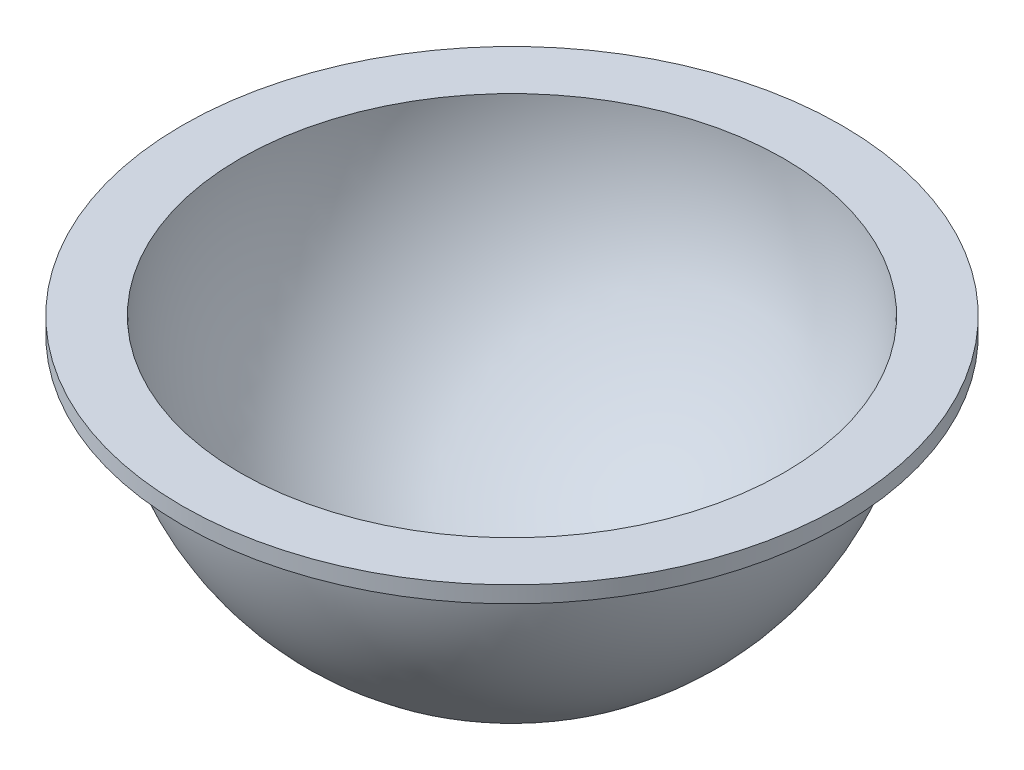
from build123d import *

# Parameters (mm, degrees)
SKETCH_2_W          = 150
SKETCH_2_H          = 150
CUT_EXTRUDE_1_DEPTH = 70
SHELL_1_T           = -4
SKETCH_3_R          = 80
SKETCH_3_R_2        = 66
EXTRUDE_1_DEPTH     = 4


with BuildPart() as part:
    # 草图1 → 旋转1 (revolve)
    with BuildSketch(Plane.XY):
        with BuildLine():
            Line((0, 70), (0, -70))
            ThreePointArc((0, -70), (70, 0), (0, 70))
        make_face()
    revolve(axis=Axis((0, 70, 0), (0, -1, 0)))

    # 草图2 → 切除-拉伸1 (cut)
    with BuildSketch(Plane(origin=(0, 0, 0), x_dir=(1, 0, 0), z_dir=(0, 1, 0))):
        Rectangle(SKETCH_2_W, SKETCH_2_H)
    extrude(amount=CUT_EXTRUDE_1_DEPTH, mode=Mode.SUBTRACT)

    # 抽壳1
    shell_1_openings = [part.faces().sort_by_distance(p)[0] for p in [
        (0, 0, 0),
    ]]
    offset(amount=SHELL_1_T, openings=shell_1_openings, kind=Kind.INTERSECTION)

    # 草图3 → 凸台-拉伸1 (add)
    with BuildSketch(Plane(origin=(0, 0, 0), x_dir=(1, 0, 0), z_dir=(0, 1, 0))):
        with Locations(Location((0, 0, 0), (0, 0, 270))):
            Circle(SKETCH_3_R)
        Circle(SKETCH_3_R_2, mode=Mode.SUBTRACT)
    extrude(amount=-EXTRUDE_1_DEPTH)


solid = part.part
